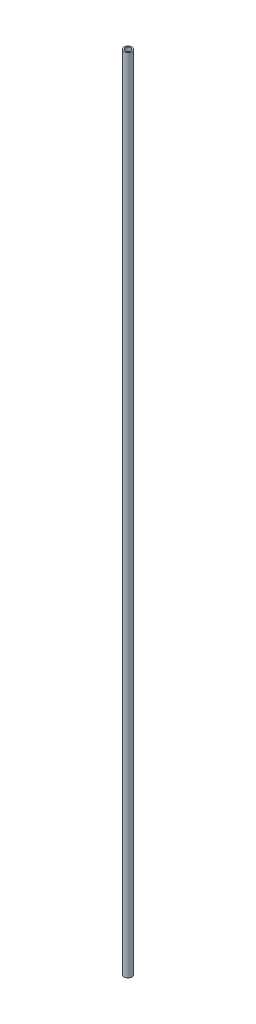
from build123d import *


with BuildPart() as part:
    # Croquis1 → Revolución1 (revolve)
    with BuildSketch(Plane.XY):
        Polygon((3.16, 34.140689655), (4.76, 34.140689655), (4.76, -905.859310345), (3.76, -905.859310345), (3.76, -897.859310345), (3.16, -897.859310345), align=None)
    revolve(axis=Axis((0, 37.259310345, 0), (0, -1, 0)))


solid = part.part
